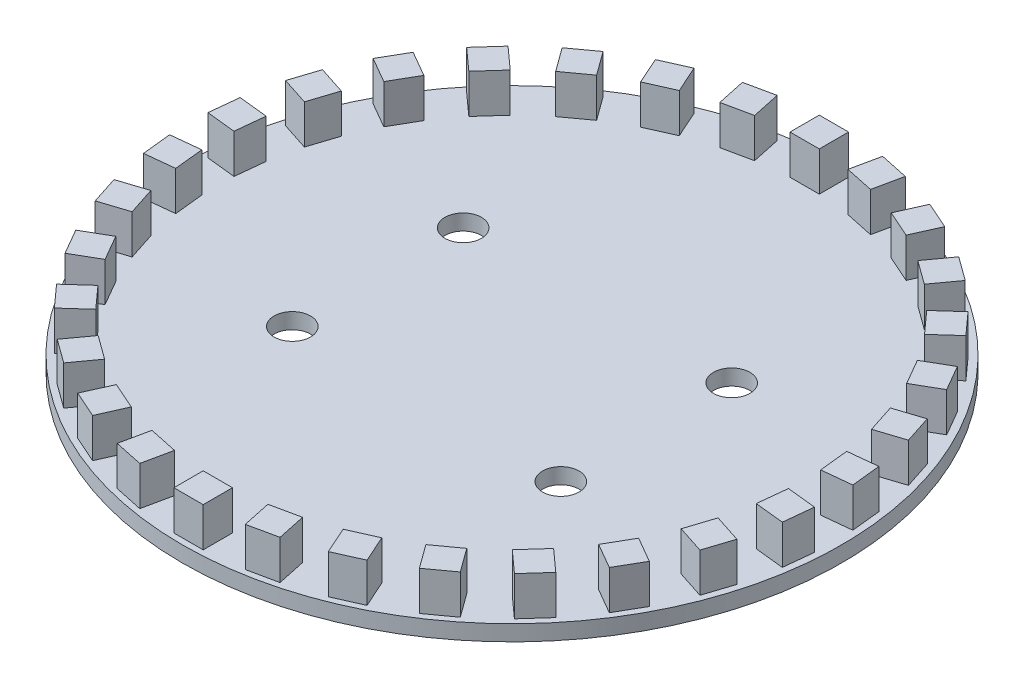
from build123d import *

# Parameters (mm, degrees)
SKETCH1_R                 = 34.29
BOSS_EXTRUDE1_DEPTH       = 1.6383
SKETCH3_W                 = 3.048
SKETCH3_H                 = 3.048
BOSS_EXTRUDE3_DEPTH       = 4.0767
CIRPATTERN1_COUNT         = 30
F_6_CLEARANCE_HOLE1_D     = 3.7973
F_6_CLEARANCE_HOLE1_DEPTH = 1.6383


with BuildPart() as part:
    # Sketch1 → Boss-Extrude1 (new body)
    with BuildSketch(Plane(origin=(0, 0, 0), x_dir=(1, 0, 0), z_dir=(0, 1, 0))):
        Circle(SKETCH1_R)
    extrude(amount=BOSS_EXTRUDE1_DEPTH)

    # Sketch3 → Boss-Extrude3 (add)
    with BuildSketch(Plane(origin=(0, 1.6383, 0), x_dir=(1, 0, 0), z_dir=(0, 1, 0))):
        with Locations((0, 31.97225)):
            Rectangle(SKETCH3_W, SKETCH3_H)
    boss_extrude3 = extrude(amount=BOSS_EXTRUDE3_DEPTH)

    # CirPattern1: Boss-Extrude3 ×30 about axis
    cirpattern1_axis = Axis((0, 0, 0.08061427), (0, 1, 0))
    for i in range(1, CIRPATTERN1_COUNT):
        add(boss_extrude3.rotate(cirpattern1_axis, i * 360 / CIRPATTERN1_COUNT))

    # #6 Clearance Hole1
    with Locations(Plane(origin=(0, 0, 0), x_dir=(-1, 0, 0), z_dir=(0, -1, 0))):
        with Locations((13.97, -8.89), (13.97, 8.89), (-13.97, 8.89), (-13.97, -8.89)):
            Hole(F_6_CLEARANCE_HOLE1_D / 2, depth=F_6_CLEARANCE_HOLE1_DEPTH)


solid = part.part
